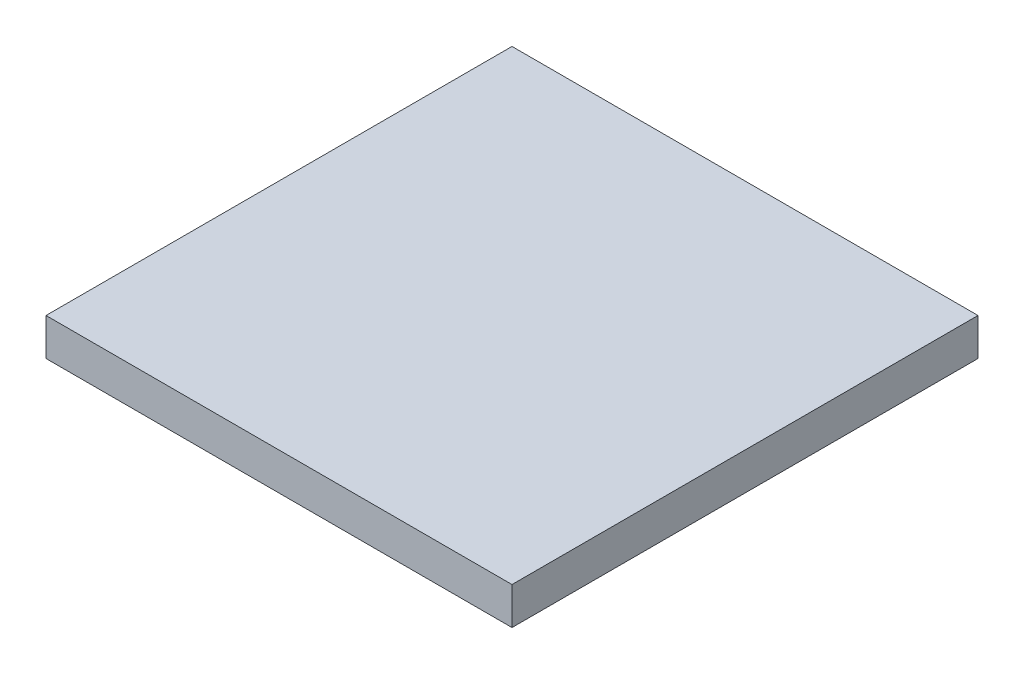
from build123d import *

# Parameters (mm, degrees)
SKETCH1_W           = 250
SKETCH1_H           = 250
BOSS_EXTRUDE1_DEPTH = 20


with BuildPart() as part:
    # Sketch1 → Boss-Extrude1 (new body)
    with BuildSketch(Plane(origin=(0, 0, 0), x_dir=(1, 0, 0), z_dir=(0, 1, 0))):
        Rectangle(SKETCH1_W, SKETCH1_H)
    extrude(amount=BOSS_EXTRUDE1_DEPTH)


solid = part.part
